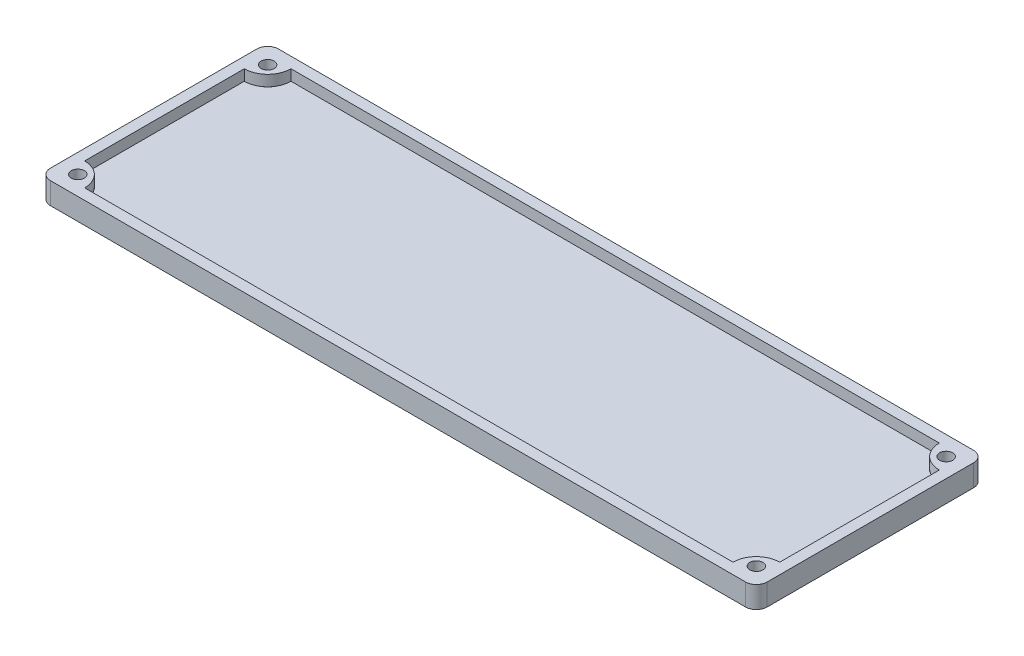
from build123d import *

# Parameters (mm, degrees)
CROQUIS1_W              = 66.01
CROQUIS1_H              = 21
SALIENTE_EXTRUIR1_DEPTH = 1
CROQUIS2_W              = 66.01
CROQUIS2_H              = 21
CROQUIS2_W_2            = 64.01
CROQUIS2_H_2            = 19
SALIENTE_EXTRUIR2_DEPTH = 1
SALIENTE_EXTRUIR3_REACH = 4
CROQUIS5_R              = 0.6
CORTAR_EXTRUIR1_DEPTH   = 3
CROQUIS6_R              = 1.1
CORTAR_EXTRUIR2_DEPTH   = 1
REDONDEO1_R             = 1


with BuildPart() as part:
    # Croquis1 → Saliente-Extruir1 (new body)
    with BuildSketch(Plane(origin=(0, 0, 0), x_dir=(1, 0, 0), z_dir=(0, 1, 0))):
        with Locations((33.005, 10.5)):
            Rectangle(CROQUIS1_W, CROQUIS1_H)
    extrude(amount=SALIENTE_EXTRUIR1_DEPTH)

    # Croquis2 → Saliente-Extruir2 (add)
    with BuildSketch(Plane(origin=(0, 1, 0), x_dir=(1, 0, 0), z_dir=(0, 1, 0))):
        with Locations((33.005, 10.5)):
            Rectangle(CROQUIS2_W, CROQUIS2_H)
        with Locations((33.005, 10.5)):
            Rectangle(CROQUIS2_W_2, CROQUIS2_H_2, mode=Mode.SUBTRACT)
    extrude(amount=SALIENTE_EXTRUIR2_DEPTH)

    # Croquis4 → Saliente-Extruir3 (add, up to next)
    with BuildSketch(Plane(origin=(0, 2, 0), x_dir=(1, 0, 0), z_dir=(0, 1, 0)), mode=Mode.PRIVATE) as saliente_extruir3_sk1:
        with BuildLine():
            Line((1, 20), (1, 17.85))
            ThreePointArc((1, 17.85), (2.52027958, 18.47972042), (3.15, 20))
            Line((3.15, 20), (1, 20))
        make_face()
    saliente_extruir3_tool1 = extrude(saliente_extruir3_sk1.sketch, amount=-SALIENTE_EXTRUIR3_REACH, mode=Mode.PRIVATE) - part.part
    add(saliente_extruir3_tool1.solids().sort_by_distance((1.912488, 2, -19.087512))[0])
    # Croquis4 → Saliente-Extruir3 (add, up to next)
    with BuildSketch(Plane(origin=(0, 2, 0), x_dir=(1, 0, 0), z_dir=(0, 1, 0)), mode=Mode.PRIVATE) as saliente_extruir3_sk2:
        with BuildLine():
            Line((1, 1), (1, 3.15))
            ThreePointArc((1, 3.15), (2.52027958, 2.52027958), (3.15, 1))
            Line((3.15, 1), (1, 1))
        make_face()
    saliente_extruir3_tool2 = extrude(saliente_extruir3_sk2.sketch, amount=-SALIENTE_EXTRUIR3_REACH, mode=Mode.PRIVATE) - part.part
    add(saliente_extruir3_tool2.solids().sort_by_distance((1.912488, 2, -1.912488))[0])
    # Croquis4 → Saliente-Extruir3 (add, up to next)
    with BuildSketch(Plane(origin=(0, 2, 0), x_dir=(1, 0, 0), z_dir=(0, 1, 0)), mode=Mode.PRIVATE) as saliente_extruir3_sk3:
        with BuildLine():
            Line((65.01, 20), (62.86, 20))
            ThreePointArc((62.86, 20), (63.48972042, 18.47972042), (65.01, 17.85))
            Line((65.01, 17.85), (65.01, 20))
        make_face()
    saliente_extruir3_tool3 = extrude(saliente_extruir3_sk3.sketch, amount=-SALIENTE_EXTRUIR3_REACH, mode=Mode.PRIVATE) - part.part
    add(saliente_extruir3_tool3.solids().sort_by_distance((64.097512, 2, -19.087512))[0])
    # Croquis4 → Saliente-Extruir3 (add, up to next)
    with BuildSketch(Plane(origin=(0, 2, 0), x_dir=(1, 0, 0), z_dir=(0, 1, 0)), mode=Mode.PRIVATE) as saliente_extruir3_sk4:
        with BuildLine():
            Line((65.01, 1), (62.86, 1))
            ThreePointArc((62.86, 1), (63.48972042, 2.52027958), (65.01, 3.15))
            Line((65.01, 3.15), (65.01, 1))
        make_face()
    saliente_extruir3_tool4 = extrude(saliente_extruir3_sk4.sketch, amount=-SALIENTE_EXTRUIR3_REACH, mode=Mode.PRIVATE) - part.part
    add(saliente_extruir3_tool4.solids().sort_by_distance((64.097512, 2, -1.912488))[0])

    # Croquis5 → Cortar-Extruir1 (cut, through all)
    with BuildSketch(Plane(origin=(0, 2, 0), x_dir=(1, 0, 0), z_dir=(0, 1, 0))):
        with Locations((1.76013979, 19.23986021)):
            Circle(CROQUIS5_R)
        with Locations((1.76013979, 1.76013979)):
            Circle(CROQUIS5_R)
        with Locations((64.24986021, 19.23986021)):
            Circle(CROQUIS5_R)
        with Locations((64.24986021, 1.76013979)):
            Circle(CROQUIS5_R)
    extrude(amount=-CORTAR_EXTRUIR1_DEPTH, mode=Mode.SUBTRACT)

    # Croquis6 → Cortar-Extruir2 (cut)
    with BuildSketch(Plane(origin=(0, 0, 0), x_dir=(-1, 0, 0), z_dir=(0, -1, 0))):
        with Locations((-64.24986021, 1.76013979)):
            Circle(CROQUIS6_R)
        with Locations((-64.24986021, 19.23986021)):
            Circle(CROQUIS6_R)
        with Locations((-1.76013979, 19.23986021)):
            Circle(CROQUIS6_R)
        with Locations((-1.76013979, 1.76013979)):
            Circle(CROQUIS6_R)
    extrude(amount=-CORTAR_EXTRUIR2_DEPTH, mode=Mode.SUBTRACT)

    # Redondeo1
    redondeo1_edges = [part.edges().sort_by_distance(p)[0] for p in [
        (0, 1, -21),
        (66.01, 1, -21),
        (66.01, 1, 0),
        (0, 1, 0),
    ]]
    fillet(redondeo1_edges, radius=REDONDEO1_R)


solid = part.part
